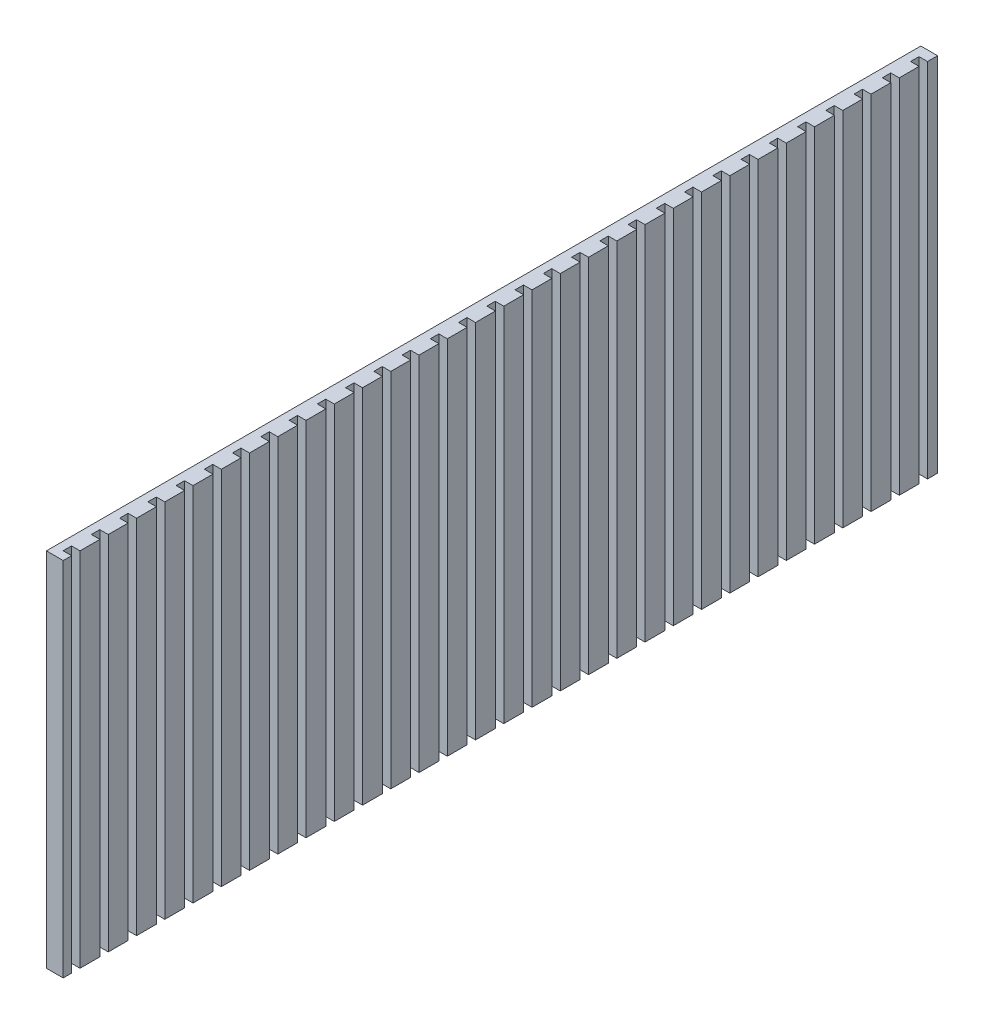
from build123d import *

# Parameters (mm, degrees)
SKETCH1_W           = 520
SKETCH1_H           = 215
BOSS_EXTRUDE1_DEPTH = 10
SKETCH2_W           = 10.131829772
SKETCH2_H           = 5
CUT_EXTRUDE1_DEPTH  = 216
LPATTERN1_COUNT     = 31
LPATTERN1_PITCH     = 16.8


with BuildPart() as part:
    # Sketch1 → Boss-Extrude1 (new body)
    with BuildSketch(Plane(origin=(0, 0, 0), x_dir=(0, 0, -1), z_dir=(1, 0, 0))):
        Rectangle(SKETCH1_W, SKETCH1_H)
    extrude(amount=BOSS_EXTRUDE1_DEPTH)

    # Sketch2 → Cut-Extrude1 (cut, through all)
    with BuildSketch(Plane(origin=(0, 107.5, 0), x_dir=(1, 0, 0), z_dir=(0, 1, 0))):
        with Locations((10, -252.5)):
            Rectangle(SKETCH2_W, SKETCH2_H)
    cut_extrude1 = extrude(amount=-CUT_EXTRUDE1_DEPTH, mode=Mode.SUBTRACT)

    # LPattern1: Cut-Extrude1 ×31
    with Locations(*[(0, 0, -i * LPATTERN1_PITCH) for i in range(1, LPATTERN1_COUNT)]):
        add(cut_extrude1, mode=Mode.SUBTRACT)


solid = part.part
